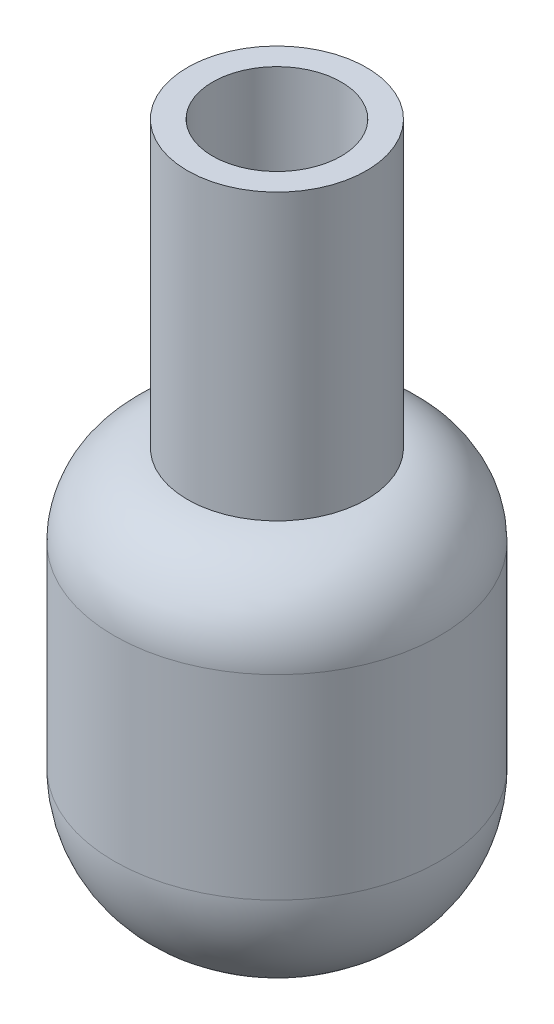
from build123d import *

# Parameters (mm, degrees)
SKETCH1_R               = 25.4
BOSS_EXTRUDE1_DEPTH     = 63.5
FILLET2_R               = 20.32
FILLET3_R               = 12.7
SKETCH2_R               = 13.97
BOSS_EXTRUDE2_DEPTH     = 44.45
SKETCH4_R               = 10.033
CUT_EXTRUDE1_DEPTH      = 50.8
CUT_EXTRUDE2_REACH      = 27.4
CUT_EXTRUDE2_END_RADIUS = 13.97
SKETCH11_R              = 5


with BuildPart() as part:
    # Sketch1 → Boss-Extrude1 (new body)
    with BuildSketch(Plane(origin=(0, 0, 0), x_dir=(1, 0, 0), z_dir=(0, 1, 0))):
        with Locations(Location((0, 0, 0), (0, 0, 270))):  # turned: the seam where the file's is
            Circle(SKETCH1_R)
    extrude(amount=BOSS_EXTRUDE1_DEPTH)

    # Fillet2
    fillet2_edges = [part.edges().sort_by_distance(p)[0] for p in [
        (0, 0, -25.4),
    ]]
    fillet(fillet2_edges, radius=FILLET2_R)

    # Fillet3
    fillet3_edges = [part.edges().sort_by_distance(p)[0] for p in [
        (0, 63.5, -25.4),
    ]]
    fillet(fillet3_edges, radius=FILLET3_R)

    # Sketch2 → Boss-Extrude2 (add)
    with BuildSketch(Plane(origin=(0, 63.5, 0), x_dir=(1, 0, 0), z_dir=(0, 1, 0))):
        with Locations(Location((0, 0, 0), (0, 0, 270))):  # turned: the seam where the file's is
            Circle(SKETCH2_R)
    extrude(amount=BOSS_EXTRUDE2_DEPTH)

    # Sketch4 → Cut-Extrude1 (cut)
    with BuildSketch(Plane(origin=(0, 107.95, 0), x_dir=(1, 0, 0), z_dir=(0, 1, 0))):
        with Locations(Location((0, 0, 0), (0, 0, 270))):  # turned: the seam where the file's is
            Circle(SKETCH4_R)
    extrude(amount=-CUT_EXTRUDE1_DEPTH, mode=Mode.SUBTRACT)

    # Cut-Extrude2: up to this cylinder (the profile starts inside it)
    cut_extrude2_end = Plane(origin=(0, 88.9, 0), z_dir=(0, -1, 0)) * Cylinder(CUT_EXTRUDE2_END_RADIUS, 83.74, mode=Mode.PRIVATE)
    # Sketch11 → Cut-Extrude2 (cut, up to the surface)
    with BuildSketch(Plane.XY, mode=Mode.PRIVATE) as cut_extrude2_sk1:
        with Locations((0, 88.9)):
            Circle(SKETCH11_R)
    cut_extrude2_tool1 = extrude(cut_extrude2_sk1.sketch, amount=-CUT_EXTRUDE2_REACH, mode=Mode.PRIVATE) & cut_extrude2_end
    add(cut_extrude2_tool1.solids().sort_by_distance((0, 88.9, 0))[0], mode=Mode.SUBTRACT)


solid = part.part
